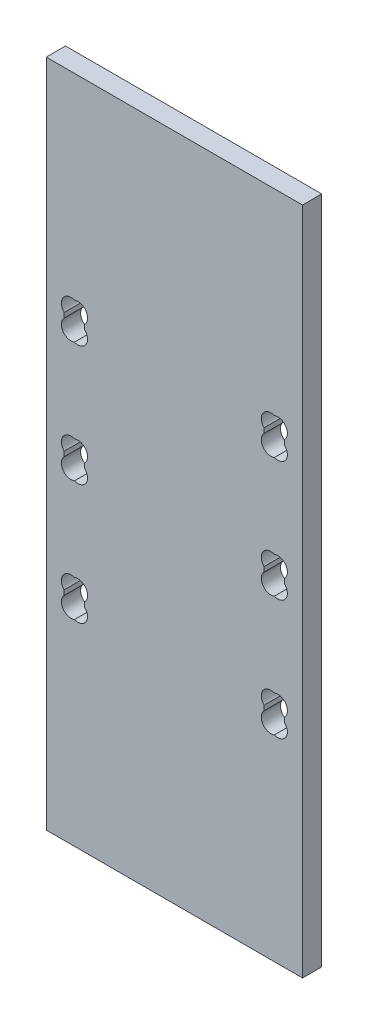
from build123d import *

# Parameters (mm, degrees)
CROQUIS2_W              = 40
CROQUIS2_H              = 104.5
SALIENTE_EXTRUIR1_DEPTH = 3
CROQUIS3_W              = 3.2
CROQUIS3_H              = 5
CORTAR_EXTRUIR1_DEPTH   = 4
CROQUIS4_R              = 1.5
CORTAR_EXTRUIR3_DEPTH   = 3
CORTAR_EXTRUIR4_DEPTH   = 4


with BuildPart() as part:
    # Croquis2 → Saliente-Extruir1 (new body)
    with BuildSketch(Plane.XY):
        Rectangle(CROQUIS2_W, CROQUIS2_H)
    extrude(amount=SALIENTE_EXTRUIR1_DEPTH)

    # Croquis3 → Cortar-Extruir1 (cut, through all)
    with BuildSketch(Plane.XY.offset(3)):
        with Locations((15.6, 18.75)):
            Rectangle(CROQUIS3_W, CROQUIS3_H)
        with Locations((15.6, 0)):
            Rectangle(CROQUIS3_W, CROQUIS3_H)
        with Locations((15.6, -18.75)):
            Rectangle(CROQUIS3_W, CROQUIS3_H)
        with Locations((-15.6, 18.75)):
            Rectangle(CROQUIS3_W, CROQUIS3_H)
        with Locations((-15.6, 0)):
            Rectangle(CROQUIS3_W, CROQUIS3_H)
        with Locations((-15.6, -18.75)):
            Rectangle(CROQUIS3_W, CROQUIS3_H)
    extrude(amount=-CORTAR_EXTRUIR1_DEPTH, mode=Mode.SUBTRACT)

    # Croquis4 → Cortar-Extruir3 (cut)
    with BuildSketch(Plane.XY.offset(3)):
        with Locations((15.060660172, 20.189339828)):
            Circle(CROQUIS4_R)
        with Locations((16.139339828, 20.189339828)):
            Circle(CROQUIS4_R)
        with Locations((16.139339828, 17.310660172)):
            Circle(CROQUIS4_R)
        with Locations((15.060660172, 17.310660172)):
            Circle(CROQUIS4_R)
    extrude(amount=-CORTAR_EXTRUIR3_DEPTH, mode=Mode.SUBTRACT)

    # Croquis5 → Cortar-Extruir4 (cut, through all)
    with BuildSketch(Plane.XY.offset(3)):
        with BuildLine():
            Line((17.2, 0.378679656), (17.2, -0.378679656))
            ThreePointArc((17.2, -0.378679656), (17.396823775, -2.257101482), (15.6, -2.839022846))
            ThreePointArc((15.6, -2.839022846), (13.803176225, -2.257101482), (14, -0.378679656))
            Line((14, -0.378679656), (14, 0.378679656))
            ThreePointArc((14, 0.378679656), (13.803176225, 2.257101482), (15.6, 2.839022846))
            ThreePointArc((15.6, 2.839022846), (17.396823775, 2.257101482), (17.2, 0.378679656))
        make_face()
        with BuildLine():
            Line((14, -18.371320344), (14, -19.128679656))
            ThreePointArc((14, -19.128679656), (13.803176225, -21.007101482), (15.6, -21.589022846))
            ThreePointArc((15.6, -21.589022846), (17.396823775, -21.007101482), (17.2, -19.128679656))
            Line((17.2, -19.128679656), (17.2, -18.371320344))
            ThreePointArc((17.2, -18.371320344), (17.396823775, -16.492898518), (15.6, -15.910977154))
            ThreePointArc((15.6, -15.910977154), (13.803176225, -16.492898518), (14, -18.371320344))
        make_face()
        with BuildLine():
            Line((-17.2, -19.128679656), (-17.2, -18.371320344))
            ThreePointArc((-17.2, -18.371320344), (-17.396823775, -16.492898518), (-15.6, -15.910977154))
            ThreePointArc((-15.6, -15.910977154), (-13.803176225, -16.492898518), (-14, -18.371320344))
            Line((-14, -18.371320344), (-14, -19.128679656))
            ThreePointArc((-14, -19.128679656), (-13.803176225, -21.007101482), (-15.6, -21.589022846))
            ThreePointArc((-15.6, -21.589022846), (-17.396823775, -21.007101482), (-17.2, -19.128679656))
        make_face()
        with BuildLine():
            Line((-14, -0.378679656), (-14, 0.378679656))
            ThreePointArc((-14, 0.378679656), (-13.803176225, 2.257101482), (-15.6, 2.839022846))
            ThreePointArc((-15.6, 2.839022846), (-17.396823775, 2.257101482), (-17.2, 0.378679656))
            Line((-17.2, 0.378679656), (-17.2, -0.378679656))
            ThreePointArc((-17.2, -0.378679656), (-17.396823775, -2.257101482), (-15.6, -2.839022846))
            ThreePointArc((-15.6, -2.839022846), (-13.803176225, -2.257101482), (-14, -0.378679656))
        make_face()
        with BuildLine():
            Line((-17.2, 18.371320344), (-17.2, 19.128679656))
            ThreePointArc((-17.2, 19.128679656), (-17.396823775, 21.007101482), (-15.6, 21.589022846))
            ThreePointArc((-15.6, 21.589022846), (-13.803176225, 21.007101482), (-14, 19.128679656))
            Line((-14, 19.128679656), (-14, 18.371320344))
            ThreePointArc((-14, 18.371320344), (-13.803176225, 16.492898518), (-15.6, 15.910977154))
            ThreePointArc((-15.6, 15.910977154), (-17.396823775, 16.492898518), (-17.2, 18.371320344))
        make_face()
    extrude(amount=-CORTAR_EXTRUIR4_DEPTH, mode=Mode.SUBTRACT)


solid = part.part
